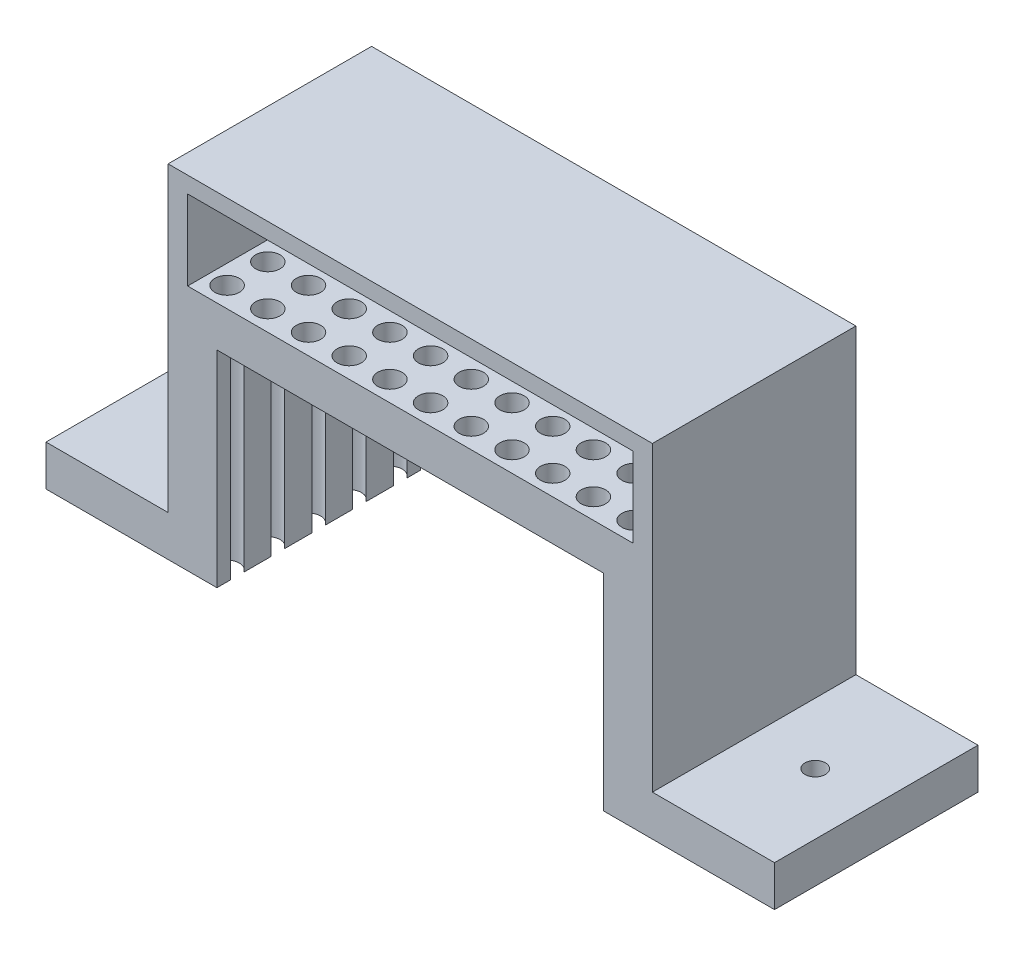
from build123d import *

# Parameters (mm, degrees)
BOSS_EXTRUDE1_DEPTH            = 25
M3_TAPPED_HOLE1_D              = 2.5
M3_TAPPED_HOLE2_D              = 2.5
SKETCH9_R                      = 1.5
CUT_EXTRUDE1_DEPTH             = 31.3
LPATTERN1_COUNT                = 6
LPATTERN1_PITCH                = 5
LPATTERN1_COL_COUNT            = 6
LPATTERN1_COL_PITCH            = 5
LPATTERN2_COUNT                = 3
LPATTERN2_PITCH                = 5
LPATTERN2_COPY_1_SKETCH_R      = 1.5
LPATTERN2_COPY_1_DEPTH         = 31.3
LPATTERN2_COPY_2_SKETCH_R      = 1.5
LPATTERN2_COPY_2_DEPTH         = 31.3
LPATTERN2_COPY_3_SKETCH_R      = 1.5
LPATTERN2_COPY_3_DEPTH         = 31.3
LPATTERN2_COPY_4_SKETCH_R      = 1.5
LPATTERN2_COPY_4_DEPTH         = 31.3
LPATTERN2_COPY_5_SKETCH_R      = 1.5
LPATTERN2_COPY_5_DEPTH         = 31.3
LPATTERN2_COPY_6_SKETCH_R      = 1.5
LPATTERN2_COPY_6_DEPTH         = 31.3
LPATTERN2_COPY_7_SKETCH_R      = 1.5
LPATTERN2_COPY_7_DEPTH         = 31.3
LPATTERN2_COPY_8_SKETCH_R      = 1.5
LPATTERN2_COPY_8_DEPTH         = 31.3
LPATTERN2_COPY_9_SKETCH_R      = 1.5
LPATTERN2_COPY_9_DEPTH         = 31.3
LPATTERN2_COPY_10_SKETCH_R     = 1.5
LPATTERN2_COPY_10_DEPTH        = 31.3
LPATTERN2_COPY_11_SKETCH_R     = 1.5
LPATTERN2_COPY_11_DEPTH        = 31.3
LPATTERN2_COPY_12_SKETCH_R     = 1.5
LPATTERN2_COPY_12_DEPTH        = 31.3
LPATTERN2_COPY_13_SKETCH_R     = 1.5
LPATTERN2_COPY_13_DEPTH        = 31.3
LPATTERN2_COPY_14_SKETCH_R     = 1.5
LPATTERN2_COPY_14_DEPTH        = 31.3
LPATTERN2_COPY_15_SKETCH_R     = 1.5
LPATTERN2_COPY_15_DEPTH        = 31.3
LPATTERN2_COPY_16_SKETCH_R     = 1.5
LPATTERN2_COPY_16_DEPTH        = 31.3
LPATTERN2_COPY_17_SKETCH_R     = 1.5
LPATTERN2_COPY_17_DEPTH        = 31.3
LPATTERN2_COPY_18_SKETCH_R     = 1.5
LPATTERN2_COPY_18_DEPTH        = 31.3
LPATTERN2_COPY_19_SKETCH_R     = 1.5
LPATTERN2_COPY_19_DEPTH        = 31.3
LPATTERN2_COPY_20_SKETCH_R     = 1.5
LPATTERN2_COPY_20_DEPTH        = 31.3
LPATTERN2_COL_COUNT            = 3
LPATTERN2_COL_PITCH            = 5
LPATTERN2_COL_COPY_1_SKETCH_R  = 1.5
LPATTERN2_COL_COPY_1_DEPTH     = 31.3
LPATTERN2_COL_COPY_2_SKETCH_R  = 1.5
LPATTERN2_COL_COPY_2_DEPTH     = 31.3
LPATTERN2_COL_COPY_3_SKETCH_R  = 1.5
LPATTERN2_COL_COPY_3_DEPTH     = 31.3
LPATTERN2_COL_COPY_4_SKETCH_R  = 1.5
LPATTERN2_COL_COPY_4_DEPTH     = 31.3
LPATTERN2_COL_COPY_5_SKETCH_R  = 1.5
LPATTERN2_COL_COPY_5_DEPTH     = 31.3
LPATTERN2_COL_COPY_6_SKETCH_R  = 1.5
LPATTERN2_COL_COPY_6_DEPTH     = 31.3
LPATTERN2_COL_COPY_7_SKETCH_R  = 1.5
LPATTERN2_COL_COPY_7_DEPTH     = 31.3
LPATTERN2_COL_COPY_8_SKETCH_R  = 1.5
LPATTERN2_COL_COPY_8_DEPTH     = 31.3
LPATTERN2_COL_COPY_9_SKETCH_R  = 1.5
LPATTERN2_COL_COPY_9_DEPTH     = 31.3
LPATTERN2_COL_COPY_10_SKETCH_R = 1.5
LPATTERN2_COL_COPY_10_DEPTH    = 31.3
LPATTERN2_COL_COPY_11_SKETCH_R = 1.5
LPATTERN2_COL_COPY_11_DEPTH    = 31.3
LPATTERN2_COL_COPY_12_SKETCH_R = 1.5
LPATTERN2_COL_COPY_12_DEPTH    = 31.3
LPATTERN2_COL_COPY_13_SKETCH_R = 1.5
LPATTERN2_COL_COPY_13_DEPTH    = 31.3
LPATTERN2_COL_COPY_14_SKETCH_R = 1.5
LPATTERN2_COL_COPY_14_DEPTH    = 31.3
LPATTERN2_COL_COPY_15_SKETCH_R = 1.5
LPATTERN2_COL_COPY_15_DEPTH    = 31.3
LPATTERN2_COL_COPY_16_SKETCH_R = 1.5
LPATTERN2_COL_COPY_16_DEPTH    = 31.3
LPATTERN2_COL_COPY_17_SKETCH_R = 1.5
LPATTERN2_COL_COPY_17_DEPTH    = 31.3
LPATTERN2_COL_COPY_18_SKETCH_R = 1.5
LPATTERN2_COL_COPY_18_DEPTH    = 31.3
LPATTERN2_COL_COPY_19_SKETCH_R = 1.5
LPATTERN2_COL_COPY_19_DEPTH    = 31.3
LPATTERN2_COL_COPY_20_SKETCH_R = 1.5
LPATTERN2_COL_COPY_20_DEPTH    = 31.3
SKETCH13_W                     = 45.5
SKETCH13_H                     = 25
BOSS_EXTRUDE2_DEPTH            = 2


with BuildPart() as part:
    # Sketch1 → Boss-Extrude1 (new body)
    with BuildSketch(Plane.XY):
        Polygon((23.75, 18.885620253), (-23.75, 18.885620253), (-23.75, -6.414379747), (-34.953721519, -6.414379747), (-44.75, -6.414379747), (-44.75, -1.414379747), (-29.75, -1.414379747), (-29.75, 35.685620253), (-22.75, 35.685620253), (-22.75, 33.685620253), (-27.35, 33.685620253), (-27.35, 23.885620253), (27.35, 23.885620253), (27.35, 33.685620253), (22.75, 33.685620253), (22.75, 35.685620253), (29.75, 35.685620253), (29.75, -1.414379747), (44.75, -1.414379747), (44.75, -6.414379747), (34.953721519, -6.414379747), (23.75, -6.414379747), align=None)
    extrude(amount=BOSS_EXTRUDE1_DEPTH)

    # M3 Tapped Hole1 (through all)
    with Locations(Plane(origin=(0, -1.414379747, 0), x_dir=(1, 0, 0), z_dir=(0, 1, 0))):
        with Locations((-37.25, -12.5)):
            Hole(M3_TAPPED_HOLE1_D / 2)

    # M3 Tapped Hole2 (through all)
    with Locations(Plane(origin=(0, 23.885620253, 0), x_dir=(1, 0, 0), z_dir=(0, 1, 0))):
        with Locations((37.25, -12.5)):
            Hole(M3_TAPPED_HOLE2_D / 2)

    # Sketch9 → Cut-Extrude1 (cut, through all)
    with BuildSketch(Plane(origin=(0, 23.885620253, 0), x_dir=(1, 0, 0), z_dir=(0, 1, 0))):
        with Locations((0, -12.5)):
            Circle(SKETCH9_R)
    cut_extrude1 = extrude(amount=-CUT_EXTRUDE1_DEPTH, mode=Mode.SUBTRACT)

    # LPattern1: Cut-Extrude1 ×6
    with Locations(*[(i * LPATTERN1_PITCH, 0, 0) for i in range(1, LPATTERN1_COUNT)]):
        add(cut_extrude1, mode=Mode.SUBTRACT)

    # LPattern1 col: Cut-Extrude1 ×6
    with Locations(*[(-i * LPATTERN1_COL_PITCH, 0, 0) for i in range(1, LPATTERN1_COL_COUNT)]):
        add(cut_extrude1, mode=Mode.SUBTRACT)

    # LPattern2: Cut-Extrude1 ×3
    with Locations(*[(0, 0, -i * LPATTERN2_PITCH) for i in range(1, LPATTERN2_COUNT)]):
        add(cut_extrude1, mode=Mode.SUBTRACT)

    # LPattern2 copy 1 sketch → LPattern2 copy 1 (cut, through all)
    with BuildSketch(Plane(origin=(5, 23.885620253, -5), x_dir=(1, 0, 0), z_dir=(0, 1, 0))):
        with Locations((0, -12.5)):
            Circle(LPATTERN2_COPY_1_SKETCH_R)
    extrude(amount=-LPATTERN2_COPY_1_DEPTH, mode=Mode.SUBTRACT)

    # LPattern2 copy 2 sketch → LPattern2 copy 2 (cut, through all)
    with BuildSketch(Plane(origin=(5, 23.885620253, -10), x_dir=(1, 0, 0), z_dir=(0, 1, 0))):
        with Locations((0, -12.5)):
            Circle(LPATTERN2_COPY_2_SKETCH_R)
    extrude(amount=-LPATTERN2_COPY_2_DEPTH, mode=Mode.SUBTRACT)

    # LPattern2 copy 3 sketch → LPattern2 copy 3 (cut, through all)
    with BuildSketch(Plane(origin=(10, 23.885620253, -5), x_dir=(1, 0, 0), z_dir=(0, 1, 0))):
        with Locations((0, -12.5)):
            Circle(LPATTERN2_COPY_3_SKETCH_R)
    extrude(amount=-LPATTERN2_COPY_3_DEPTH, mode=Mode.SUBTRACT)

    # LPattern2 copy 4 sketch → LPattern2 copy 4 (cut, through all)
    with BuildSketch(Plane(origin=(10, 23.885620253, -10), x_dir=(1, 0, 0), z_dir=(0, 1, 0))):
        with Locations((0, -12.5)):
            Circle(LPATTERN2_COPY_4_SKETCH_R)
    extrude(amount=-LPATTERN2_COPY_4_DEPTH, mode=Mode.SUBTRACT)

    # LPattern2 copy 5 sketch → LPattern2 copy 5 (cut, through all)
    with BuildSketch(Plane(origin=(15, 23.885620253, -5), x_dir=(1, 0, 0), z_dir=(0, 1, 0))):
        with Locations((0, -12.5)):
            Circle(LPATTERN2_COPY_5_SKETCH_R)
    extrude(amount=-LPATTERN2_COPY_5_DEPTH, mode=Mode.SUBTRACT)

    # LPattern2 copy 6 sketch → LPattern2 copy 6 (cut, through all)
    with BuildSketch(Plane(origin=(15, 23.885620253, -10), x_dir=(1, 0, 0), z_dir=(0, 1, 0))):
        with Locations((0, -12.5)):
            Circle(LPATTERN2_COPY_6_SKETCH_R)
    extrude(amount=-LPATTERN2_COPY_6_DEPTH, mode=Mode.SUBTRACT)

    # LPattern2 copy 7 sketch → LPattern2 copy 7 (cut, through all)
    with BuildSketch(Plane(origin=(20, 23.885620253, -5), x_dir=(1, 0, 0), z_dir=(0, 1, 0))):
        with Locations((0, -12.5)):
            Circle(LPATTERN2_COPY_7_SKETCH_R)
    extrude(amount=-LPATTERN2_COPY_7_DEPTH, mode=Mode.SUBTRACT)

    # LPattern2 copy 8 sketch → LPattern2 copy 8 (cut, through all)
    with BuildSketch(Plane(origin=(20, 23.885620253, -10), x_dir=(1, 0, 0), z_dir=(0, 1, 0))):
        with Locations((0, -12.5)):
            Circle(LPATTERN2_COPY_8_SKETCH_R)
    extrude(amount=-LPATTERN2_COPY_8_DEPTH, mode=Mode.SUBTRACT)

    # LPattern2 copy 9 sketch → LPattern2 copy 9 (cut, through all)
    with BuildSketch(Plane(origin=(25, 23.885620253, -5), x_dir=(1, 0, 0), z_dir=(0, 1, 0))):
        with Locations((0, -12.5)):
            Circle(LPATTERN2_COPY_9_SKETCH_R)
    extrude(amount=-LPATTERN2_COPY_9_DEPTH, mode=Mode.SUBTRACT)

    # LPattern2 copy 10 sketch → LPattern2 copy 10 (cut, through all)
    with BuildSketch(Plane(origin=(25, 23.885620253, -10), x_dir=(1, 0, 0), z_dir=(0, 1, 0))):
        with Locations((0, -12.5)):
            Circle(LPATTERN2_COPY_10_SKETCH_R)
    extrude(amount=-LPATTERN2_COPY_10_DEPTH, mode=Mode.SUBTRACT)

    # LPattern2 copy 11 sketch → LPattern2 copy 11 (cut, through all)
    with BuildSketch(Plane(origin=(-5, 23.885620253, -5), x_dir=(1, 0, 0), z_dir=(0, 1, 0))):
        with Locations((0, -12.5)):
            Circle(LPATTERN2_COPY_11_SKETCH_R)
    extrude(amount=-LPATTERN2_COPY_11_DEPTH, mode=Mode.SUBTRACT)

    # LPattern2 copy 12 sketch → LPattern2 copy 12 (cut, through all)
    with BuildSketch(Plane(origin=(-5, 23.885620253, -10), x_dir=(1, 0, 0), z_dir=(0, 1, 0))):
        with Locations((0, -12.5)):
            Circle(LPATTERN2_COPY_12_SKETCH_R)
    extrude(amount=-LPATTERN2_COPY_12_DEPTH, mode=Mode.SUBTRACT)

    # LPattern2 copy 13 sketch → LPattern2 copy 13 (cut, through all)
    with BuildSketch(Plane(origin=(-10, 23.885620253, -5), x_dir=(1, 0, 0), z_dir=(0, 1, 0))):
        with Locations((0, -12.5)):
            Circle(LPATTERN2_COPY_13_SKETCH_R)
    extrude(amount=-LPATTERN2_COPY_13_DEPTH, mode=Mode.SUBTRACT)

    # LPattern2 copy 14 sketch → LPattern2 copy 14 (cut, through all)
    with BuildSketch(Plane(origin=(-10, 23.885620253, -10), x_dir=(1, 0, 0), z_dir=(0, 1, 0))):
        with Locations((0, -12.5)):
            Circle(LPATTERN2_COPY_14_SKETCH_R)
    extrude(amount=-LPATTERN2_COPY_14_DEPTH, mode=Mode.SUBTRACT)

    # LPattern2 copy 15 sketch → LPattern2 copy 15 (cut, through all)
    with BuildSketch(Plane(origin=(-15, 23.885620253, -5), x_dir=(1, 0, 0), z_dir=(0, 1, 0))):
        with Locations((0, -12.5)):
            Circle(LPATTERN2_COPY_15_SKETCH_R)
    extrude(amount=-LPATTERN2_COPY_15_DEPTH, mode=Mode.SUBTRACT)

    # LPattern2 copy 16 sketch → LPattern2 copy 16 (cut, through all)
    with BuildSketch(Plane(origin=(-15, 23.885620253, -10), x_dir=(1, 0, 0), z_dir=(0, 1, 0))):
        with Locations((0, -12.5)):
            Circle(LPATTERN2_COPY_16_SKETCH_R)
    extrude(amount=-LPATTERN2_COPY_16_DEPTH, mode=Mode.SUBTRACT)

    # LPattern2 copy 17 sketch → LPattern2 copy 17 (cut, through all)
    with BuildSketch(Plane(origin=(-20, 23.885620253, -5), x_dir=(1, 0, 0), z_dir=(0, 1, 0))):
        with Locations((0, -12.5)):
            Circle(LPATTERN2_COPY_17_SKETCH_R)
    extrude(amount=-LPATTERN2_COPY_17_DEPTH, mode=Mode.SUBTRACT)

    # LPattern2 copy 18 sketch → LPattern2 copy 18 (cut, through all)
    with BuildSketch(Plane(origin=(-20, 23.885620253, -10), x_dir=(1, 0, 0), z_dir=(0, 1, 0))):
        with Locations((0, -12.5)):
            Circle(LPATTERN2_COPY_18_SKETCH_R)
    extrude(amount=-LPATTERN2_COPY_18_DEPTH, mode=Mode.SUBTRACT)

    # LPattern2 copy 19 sketch → LPattern2 copy 19 (cut, through all)
    with BuildSketch(Plane(origin=(-25, 23.885620253, -5), x_dir=(1, 0, 0), z_dir=(0, 1, 0))):
        with Locations((0, -12.5)):
            Circle(LPATTERN2_COPY_19_SKETCH_R)
    extrude(amount=-LPATTERN2_COPY_19_DEPTH, mode=Mode.SUBTRACT)

    # LPattern2 copy 20 sketch → LPattern2 copy 20 (cut, through all)
    with BuildSketch(Plane(origin=(-25, 23.885620253, -10), x_dir=(1, 0, 0), z_dir=(0, 1, 0))):
        with Locations((0, -12.5)):
            Circle(LPATTERN2_COPY_20_SKETCH_R)
    extrude(amount=-LPATTERN2_COPY_20_DEPTH, mode=Mode.SUBTRACT)

    # LPattern2 col: Cut-Extrude1 ×3
    with Locations(*[(0, 0, i * LPATTERN2_COL_PITCH) for i in range(1, LPATTERN2_COL_COUNT)]):
        add(cut_extrude1, mode=Mode.SUBTRACT)

    # LPattern2 col copy 1 sketch → LPattern2 col copy 1 (cut, through all)
    with BuildSketch(Plane(origin=(5, 23.885620253, 5), x_dir=(1, 0, 0), z_dir=(0, 1, 0))):
        with Locations((0, -12.5)):
            Circle(LPATTERN2_COL_COPY_1_SKETCH_R)
    extrude(amount=-LPATTERN2_COL_COPY_1_DEPTH, mode=Mode.SUBTRACT)

    # LPattern2 col copy 2 sketch → LPattern2 col copy 2 (cut, through all)
    with BuildSketch(Plane(origin=(5, 23.885620253, 10), x_dir=(1, 0, 0), z_dir=(0, 1, 0))):
        with Locations((0, -12.5)):
            Circle(LPATTERN2_COL_COPY_2_SKETCH_R)
    extrude(amount=-LPATTERN2_COL_COPY_2_DEPTH, mode=Mode.SUBTRACT)

    # LPattern2 col copy 3 sketch → LPattern2 col copy 3 (cut, through all)
    with BuildSketch(Plane(origin=(10, 23.885620253, 5), x_dir=(1, 0, 0), z_dir=(0, 1, 0))):
        with Locations((0, -12.5)):
            Circle(LPATTERN2_COL_COPY_3_SKETCH_R)
    extrude(amount=-LPATTERN2_COL_COPY_3_DEPTH, mode=Mode.SUBTRACT)

    # LPattern2 col copy 4 sketch → LPattern2 col copy 4 (cut, through all)
    with BuildSketch(Plane(origin=(10, 23.885620253, 10), x_dir=(1, 0, 0), z_dir=(0, 1, 0))):
        with Locations((0, -12.5)):
            Circle(LPATTERN2_COL_COPY_4_SKETCH_R)
    extrude(amount=-LPATTERN2_COL_COPY_4_DEPTH, mode=Mode.SUBTRACT)

    # LPattern2 col copy 5 sketch → LPattern2 col copy 5 (cut, through all)
    with BuildSketch(Plane(origin=(15, 23.885620253, 5), x_dir=(1, 0, 0), z_dir=(0, 1, 0))):
        with Locations((0, -12.5)):
            Circle(LPATTERN2_COL_COPY_5_SKETCH_R)
    extrude(amount=-LPATTERN2_COL_COPY_5_DEPTH, mode=Mode.SUBTRACT)

    # LPattern2 col copy 6 sketch → LPattern2 col copy 6 (cut, through all)
    with BuildSketch(Plane(origin=(15, 23.885620253, 10), x_dir=(1, 0, 0), z_dir=(0, 1, 0))):
        with Locations((0, -12.5)):
            Circle(LPATTERN2_COL_COPY_6_SKETCH_R)
    extrude(amount=-LPATTERN2_COL_COPY_6_DEPTH, mode=Mode.SUBTRACT)

    # LPattern2 col copy 7 sketch → LPattern2 col copy 7 (cut, through all)
    with BuildSketch(Plane(origin=(20, 23.885620253, 5), x_dir=(1, 0, 0), z_dir=(0, 1, 0))):
        with Locations((0, -12.5)):
            Circle(LPATTERN2_COL_COPY_7_SKETCH_R)
    extrude(amount=-LPATTERN2_COL_COPY_7_DEPTH, mode=Mode.SUBTRACT)

    # LPattern2 col copy 8 sketch → LPattern2 col copy 8 (cut, through all)
    with BuildSketch(Plane(origin=(20, 23.885620253, 10), x_dir=(1, 0, 0), z_dir=(0, 1, 0))):
        with Locations((0, -12.5)):
            Circle(LPATTERN2_COL_COPY_8_SKETCH_R)
    extrude(amount=-LPATTERN2_COL_COPY_8_DEPTH, mode=Mode.SUBTRACT)

    # LPattern2 col copy 9 sketch → LPattern2 col copy 9 (cut, through all)
    with BuildSketch(Plane(origin=(25, 23.885620253, 5), x_dir=(1, 0, 0), z_dir=(0, 1, 0))):
        with Locations((0, -12.5)):
            Circle(LPATTERN2_COL_COPY_9_SKETCH_R)
    extrude(amount=-LPATTERN2_COL_COPY_9_DEPTH, mode=Mode.SUBTRACT)

    # LPattern2 col copy 10 sketch → LPattern2 col copy 10 (cut, through all)
    with BuildSketch(Plane(origin=(25, 23.885620253, 10), x_dir=(1, 0, 0), z_dir=(0, 1, 0))):
        with Locations((0, -12.5)):
            Circle(LPATTERN2_COL_COPY_10_SKETCH_R)
    extrude(amount=-LPATTERN2_COL_COPY_10_DEPTH, mode=Mode.SUBTRACT)

    # LPattern2 col copy 11 sketch → LPattern2 col copy 11 (cut, through all)
    with BuildSketch(Plane(origin=(-5, 23.885620253, 5), x_dir=(1, 0, 0), z_dir=(0, 1, 0))):
        with Locations((0, -12.5)):
            Circle(LPATTERN2_COL_COPY_11_SKETCH_R)
    extrude(amount=-LPATTERN2_COL_COPY_11_DEPTH, mode=Mode.SUBTRACT)

    # LPattern2 col copy 12 sketch → LPattern2 col copy 12 (cut, through all)
    with BuildSketch(Plane(origin=(-5, 23.885620253, 10), x_dir=(1, 0, 0), z_dir=(0, 1, 0))):
        with Locations((0, -12.5)):
            Circle(LPATTERN2_COL_COPY_12_SKETCH_R)
    extrude(amount=-LPATTERN2_COL_COPY_12_DEPTH, mode=Mode.SUBTRACT)

    # LPattern2 col copy 13 sketch → LPattern2 col copy 13 (cut, through all)
    with BuildSketch(Plane(origin=(-10, 23.885620253, 5), x_dir=(1, 0, 0), z_dir=(0, 1, 0))):
        with Locations((0, -12.5)):
            Circle(LPATTERN2_COL_COPY_13_SKETCH_R)
    extrude(amount=-LPATTERN2_COL_COPY_13_DEPTH, mode=Mode.SUBTRACT)

    # LPattern2 col copy 14 sketch → LPattern2 col copy 14 (cut, through all)
    with BuildSketch(Plane(origin=(-10, 23.885620253, 10), x_dir=(1, 0, 0), z_dir=(0, 1, 0))):
        with Locations((0, -12.5)):
            Circle(LPATTERN2_COL_COPY_14_SKETCH_R)
    extrude(amount=-LPATTERN2_COL_COPY_14_DEPTH, mode=Mode.SUBTRACT)

    # LPattern2 col copy 15 sketch → LPattern2 col copy 15 (cut, through all)
    with BuildSketch(Plane(origin=(-15, 23.885620253, 5), x_dir=(1, 0, 0), z_dir=(0, 1, 0))):
        with Locations((0, -12.5)):
            Circle(LPATTERN2_COL_COPY_15_SKETCH_R)
    extrude(amount=-LPATTERN2_COL_COPY_15_DEPTH, mode=Mode.SUBTRACT)

    # LPattern2 col copy 16 sketch → LPattern2 col copy 16 (cut, through all)
    with BuildSketch(Plane(origin=(-15, 23.885620253, 10), x_dir=(1, 0, 0), z_dir=(0, 1, 0))):
        with Locations((0, -12.5)):
            Circle(LPATTERN2_COL_COPY_16_SKETCH_R)
    extrude(amount=-LPATTERN2_COL_COPY_16_DEPTH, mode=Mode.SUBTRACT)

    # LPattern2 col copy 17 sketch → LPattern2 col copy 17 (cut, through all)
    with BuildSketch(Plane(origin=(-20, 23.885620253, 5), x_dir=(1, 0, 0), z_dir=(0, 1, 0))):
        with Locations((0, -12.5)):
            Circle(LPATTERN2_COL_COPY_17_SKETCH_R)
    extrude(amount=-LPATTERN2_COL_COPY_17_DEPTH, mode=Mode.SUBTRACT)

    # LPattern2 col copy 18 sketch → LPattern2 col copy 18 (cut, through all)
    with BuildSketch(Plane(origin=(-20, 23.885620253, 10), x_dir=(1, 0, 0), z_dir=(0, 1, 0))):
        with Locations((0, -12.5)):
            Circle(LPATTERN2_COL_COPY_18_SKETCH_R)
    extrude(amount=-LPATTERN2_COL_COPY_18_DEPTH, mode=Mode.SUBTRACT)

    # LPattern2 col copy 19 sketch → LPattern2 col copy 19 (cut, through all)
    with BuildSketch(Plane(origin=(-25, 23.885620253, 5), x_dir=(1, 0, 0), z_dir=(0, 1, 0))):
        with Locations((0, -12.5)):
            Circle(LPATTERN2_COL_COPY_19_SKETCH_R)
    extrude(amount=-LPATTERN2_COL_COPY_19_DEPTH, mode=Mode.SUBTRACT)

    # LPattern2 col copy 20 sketch → LPattern2 col copy 20 (cut, through all)
    with BuildSketch(Plane(origin=(-25, 23.885620253, 10), x_dir=(1, 0, 0), z_dir=(0, 1, 0))):
        with Locations((0, -12.5)):
            Circle(LPATTERN2_COL_COPY_20_SKETCH_R)
    extrude(amount=-LPATTERN2_COL_COPY_20_DEPTH, mode=Mode.SUBTRACT)

    # Sketch13 → Boss-Extrude2 (add)
    with BuildSketch(Plane(origin=(0, 35.685620253, 0), x_dir=(1, 0, 0), z_dir=(0, 1, 0))):
        with Locations((0, -12.5)):
            Rectangle(SKETCH13_W, SKETCH13_H)
    extrude(amount=-BOSS_EXTRUDE2_DEPTH)


solid = part.part
